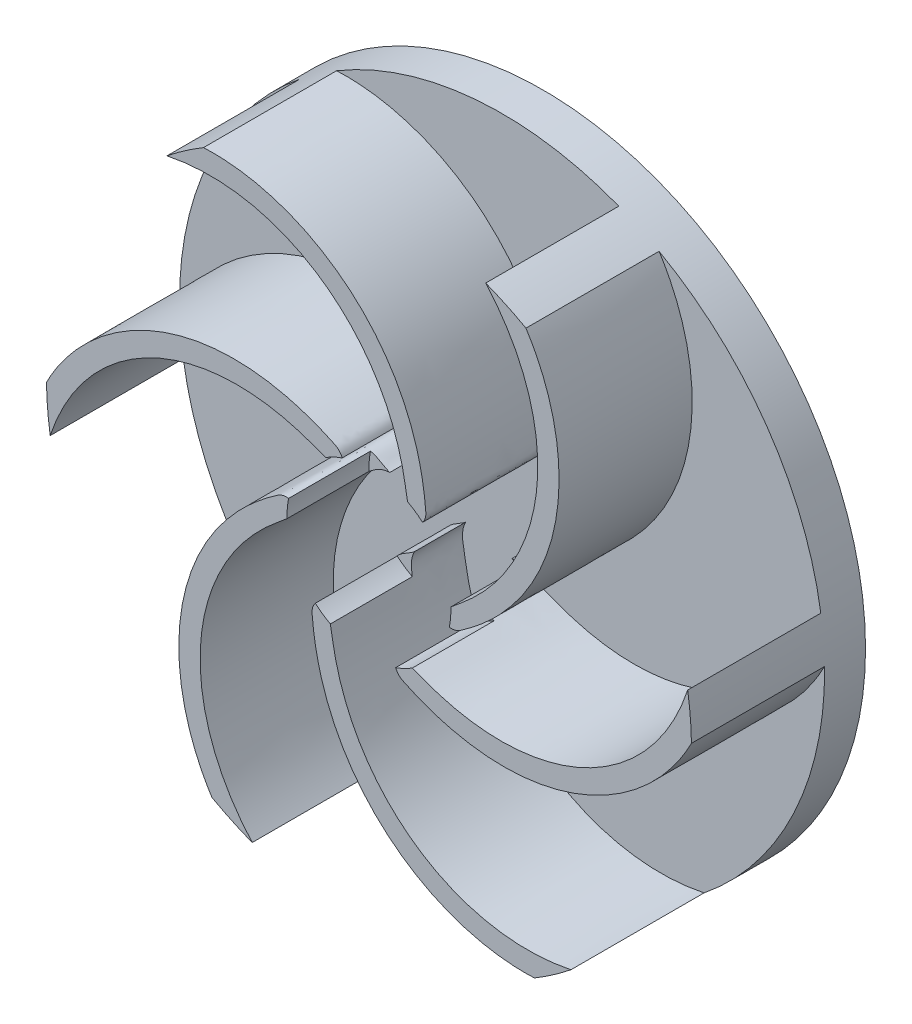
from build123d import *

# Parameters (mm, degrees)
SKETCH1_R          = 31.5
EXTRUDE1_DEPTH     = 4
EXTRUDE2_DEPTH     = 13
CIRPATTERN1_COUNT  = 6
SKETCH9_R          = 8
CUT_EXTRUDE1_DEPTH = 8


with BuildPart() as part:
    # Sketch1 → Extrude1 (new body)
    with BuildSketch(Plane.XY):
        Circle(SKETCH1_R)
    extrude(amount=EXTRUDE1_DEPTH)

    # Sketch8 → Extrude2 (add)
    with BuildSketch(Plane.XY.offset(4)):
        with BuildLine():
            ThreePointArc((-15.335083755, -27.515181378), (-13.401012303, -28.5072424), (-11.403128973, -29.363559894))
            add(Edge.make_bspline(
                [(-11.403128973, -29.363559894), (-18.960599099, -20.910233685), (-18.057148894, -8.477271422), (-7.839740111, -0.161000485), (-7.171379792, 0.610841586), (-5.963772485, 0.658344705)],
                knots=[0, 0, 0, 0, 0.892040708, 0.892040708, 1, 1, 1, 1], degree=3))
            add(Edge.make_bspline(
                [(-15.335083755, -27.515181378), (-20.746685268, -19.074778053), (-19.86094526, -6.243260483), (-7.793442469, 2.03080533), (-6.812175467, 0.957264639), (-5.963772485, 0.658344705)],
                knots=[0, 0, 0, 0, 0.907416994, 0.907416994, 1, 1, 1, 1], degree=3))
        make_face()
    extrude2 = extrude(amount=EXTRUDE2_DEPTH)

    # CirPattern1: Extrude2 ×6 about axis
    cirpattern1_axis = Axis((0, 0, 4), (0, 0, -1))
    for i in range(1, CIRPATTERN1_COUNT):
        add(extrude2.rotate(cirpattern1_axis, i * 360 / CIRPATTERN1_COUNT))

    # Sketch9 → Cut-Extrude1 (cut)
    with BuildSketch(Plane.XY.offset(17)):
        Circle(SKETCH9_R)
    extrude(amount=-CUT_EXTRUDE1_DEPTH, mode=Mode.SUBTRACT)


solid = part.part
